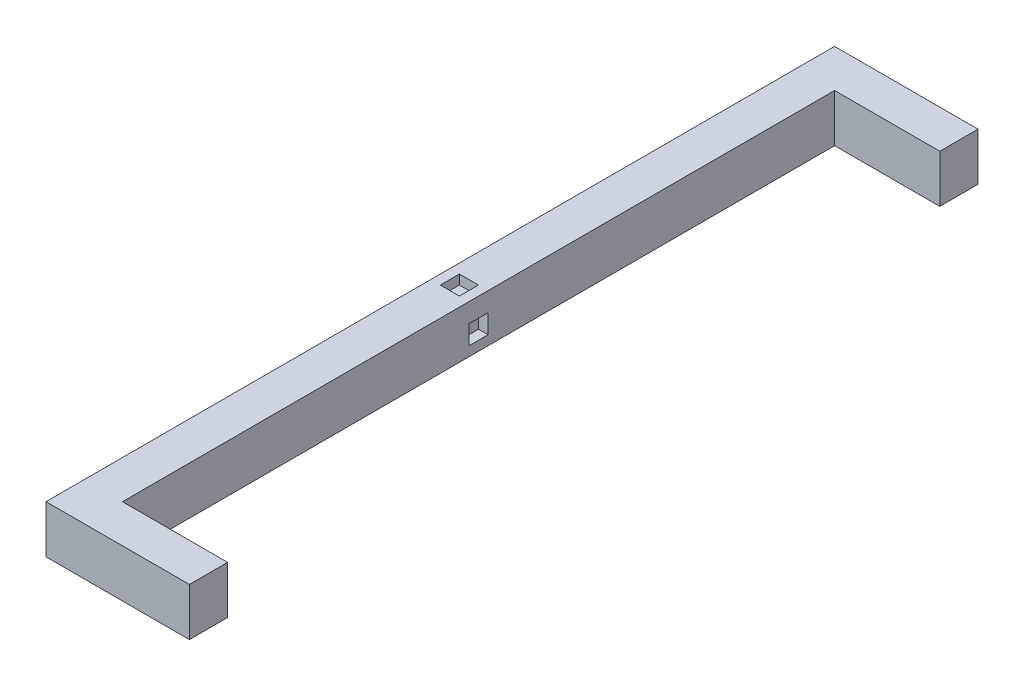
from build123d import *

# Parameters (mm, degrees)
SKETCH1_W           = 8
SKETCH1_H           = 10
BOSS_EXTRUDE1_DEPTH = 165
SKETCH2_W           = 8
SKETCH2_H           = 10
BOSS_EXTRUDE2_DEPTH = 22
SKETCH3_W           = 4
SKETCH3_H           = 4
CUT_EXTRUDE1_DEPTH  = 2
SKETCH5_W           = 4
SKETCH5_H           = 4
CUT_EXTRUDE2_DEPTH  = 2


with BuildPart() as part:
    # Sketch1 → Boss-Extrude1 (new body)
    with BuildSketch(Plane.XY):
        with Locations((4, 5)):
            Rectangle(SKETCH1_W, SKETCH1_H)
    extrude(amount=BOSS_EXTRUDE1_DEPTH)

    # Sketch2 → Boss-Extrude2 (add)
    with BuildSketch(Plane(origin=(8, 0, 0), x_dir=(0, 0, -1), z_dir=(1, 0, 0))):
        with Locations((-4, 5)):
            Rectangle(SKETCH2_W, SKETCH2_H)
        with Locations((-161, 5)):
            Rectangle(SKETCH2_W, SKETCH2_H)
    extrude(amount=BOSS_EXTRUDE2_DEPTH)

    # Sketch3 → Cut-Extrude1 (cut)
    with BuildSketch(Plane(origin=(0, 10, 0), x_dir=(1, 0, 0), z_dir=(0, 1, 0))):
        with Locations((4, -82.5)):
            Rectangle(SKETCH3_W, SKETCH3_H)
    extrude(amount=-CUT_EXTRUDE1_DEPTH, mode=Mode.SUBTRACT)

    # Sketch5 → Cut-Extrude2 (cut)
    with BuildSketch(Plane(origin=(8, 0, 0), x_dir=(0, 0, -1), z_dir=(1, 0, 0))):
        with Locations((-82.5, 4)):
            Rectangle(SKETCH5_W, SKETCH5_H)
    extrude(amount=-CUT_EXTRUDE2_DEPTH, mode=Mode.SUBTRACT)


solid = part.part
